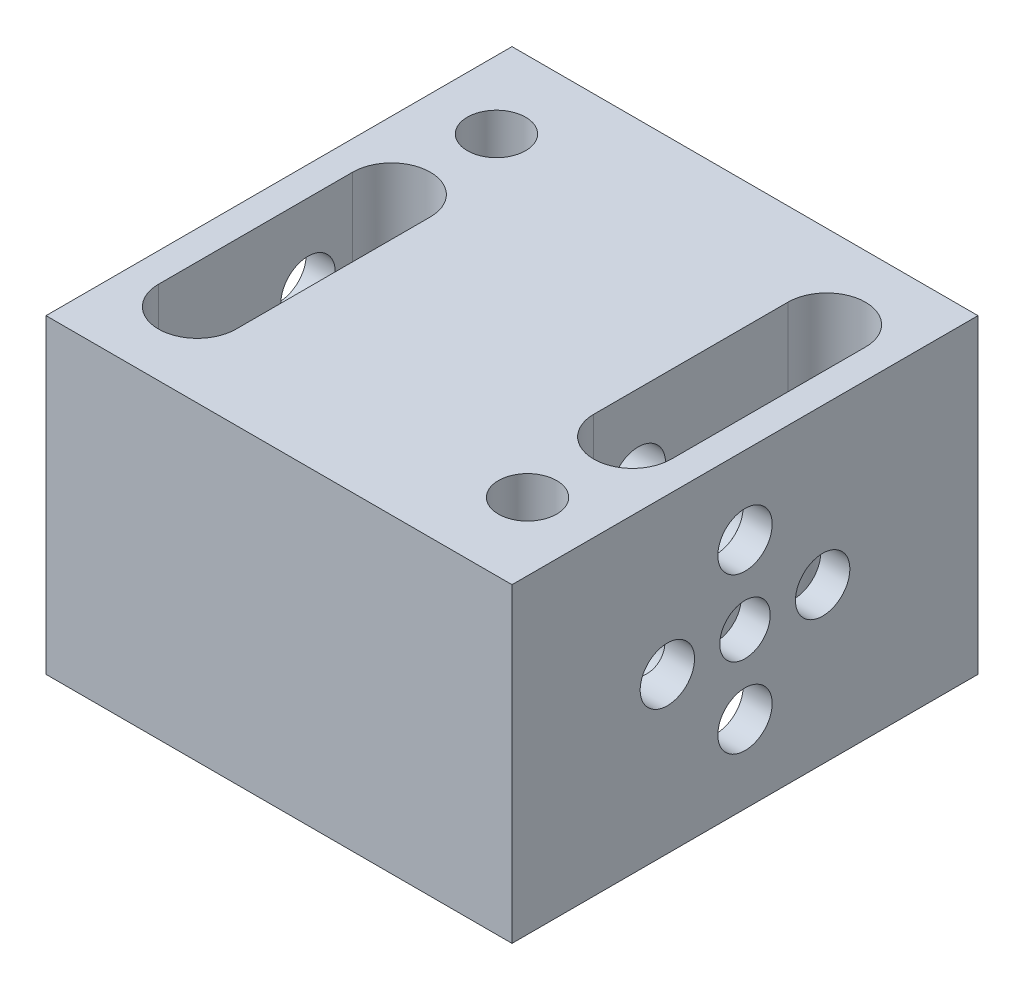
from build123d import *
from build123d.topology import SkipClean

# Parameters (mm, degrees)
SKETCH_1_W          = 76.2
SKETCH_1_H          = 50.8
SKETCH_1_R          = 4.1275
SKETCH_1_R_2        = 4.445
EXTRUDE_1_DEPTH     = 76.2
SKETCH_3_W          = 76.2
SKETCH_3_H          = 76.2
SKETCH_3_R          = 4.7625
EXTRUDE_2_DEPTH     = 50.8
SKETCH_1_4_R        = 4.1275
SKETCH_1_4_R_2      = 4.445
CUT_EXTRUDE_2_DEPTH = 76.2
SKETCH_10_R         = 4.7625
CUT_EXTRUDE_3_DEPTH = 50.8


with BuildPart() as part:
    # 草图1 → 凸台-拉伸1 (new body)
    with BuildSketch(Plane(origin=(0, 0, 0), x_dir=(0, 0, -1), z_dir=(1, 0, 0))):
        with Locations((38.1, 25.4)):
            Rectangle(SKETCH_1_W, SKETCH_1_H)
        with Locations((38.1, 25.4)):
            Circle(SKETCH_1_R, mode=Mode.SUBTRACT)
        with Locations((25.4, 25.4)):
            Circle(SKETCH_1_R_2, mode=Mode.SUBTRACT)
        with Locations((50.8, 25.4)):
            Circle(SKETCH_1_R_2, mode=Mode.SUBTRACT)
        with Locations((38.1, 38.1)):
            Circle(SKETCH_1_R_2, mode=Mode.SUBTRACT)
        with Locations((38.1, 12.7)):
            Circle(SKETCH_1_R_2, mode=Mode.SUBTRACT)
    extrude(amount=EXTRUDE_1_DEPTH)

    # 草图3 → 凸台-拉伸2 (add)
    with BuildSketch(Plane(origin=(0, 0, 0), x_dir=(1, 0, 0), z_dir=(0, 1, 0))):
        with Locations((38.1, 38.1)):
            Rectangle(SKETCH_3_W, SKETCH_3_H)
        with Locations((11.0998, 62.5602)):
            Circle(SKETCH_3_R, mode=Mode.SUBTRACT)
        with Locations((65.1002, 13.6398)):
            Circle(SKETCH_3_R, mode=Mode.SUBTRACT)
        with BuildLine():
            Line((17.4498, 45.3898), (17.4498, 13.6398))
            ThreePointArc((17.4498, 13.6398), (11.0998, 7.2898), (4.7498, 13.6398))
            Line((4.7498, 13.6398), (4.7498, 45.3898))
            ThreePointArc((4.7498, 45.3898), (11.0998, 51.7398), (17.4498, 45.3898))
        make_face(mode=Mode.SUBTRACT)
        with BuildLine():
            Line((58.7502, 30.8102), (58.7502, 62.5602))
            ThreePointArc((58.7502, 62.5602), (65.1002, 68.9102), (71.4502, 62.5602))
            Line((71.4502, 62.5602), (71.4502, 30.8102))
            ThreePointArc((71.4502, 30.8102), (65.1002, 24.4602), (58.7502, 30.8102))
        make_face(mode=Mode.SUBTRACT)
    extrude(amount=EXTRUDE_2_DEPTH)

    # 草图1<4> → 切除-拉伸2 (cut)
    with SkipClean():  # the faces are left unmerged after this step: merging them gives an invalid solid
        with BuildSketch(Plane(origin=(0, 0, 0), x_dir=(0, 0, -1), z_dir=(1, 0, 0))):
            with Locations((38.1, 25.4)):
                Circle(SKETCH_1_4_R)
            with Locations((25.4, 25.4)):
                Circle(SKETCH_1_4_R_2)
            with Locations((50.8, 25.4)):
                Circle(SKETCH_1_4_R_2)
            with Locations((38.1, 38.1)):
                Circle(SKETCH_1_4_R_2)
            with Locations((38.1, 12.7)):
                Circle(SKETCH_1_4_R_2)
        extrude(amount=CUT_EXTRUDE_2_DEPTH, mode=Mode.SUBTRACT)

    # 草图10 → 切除-拉伸3 (cut)
    with BuildSketch(Plane(origin=(0, 0, 0), x_dir=(1, 0, 0), z_dir=(0, 1, 0))):
        with Locations((11.0998, 62.5602)):
            Circle(SKETCH_10_R)
        with Locations((65.1002, 13.6398)):
            Circle(SKETCH_10_R)
        with BuildLine():
            Line((4.7498, 13.6398), (4.7498, 45.3898))
            ThreePointArc((4.7498, 45.3898), (11.0998, 51.7398), (17.4498, 45.3898))
            Line((17.4498, 45.3898), (17.4498, 13.6398))
            ThreePointArc((17.4498, 13.6398), (11.0998, 7.2898), (4.7498, 13.6398))
        make_face()
        with BuildLine():
            Line((71.4502, 62.5602), (71.4502, 30.8102))
            ThreePointArc((71.4502, 30.8102), (65.1002, 24.4602), (58.7502, 30.8102))
            Line((58.7502, 30.8102), (58.7502, 62.5602))
            ThreePointArc((58.7502, 62.5602), (65.1002, 68.9102), (71.4502, 62.5602))
        make_face()
    extrude(amount=CUT_EXTRUDE_3_DEPTH, mode=Mode.SUBTRACT)


solid = part.part
